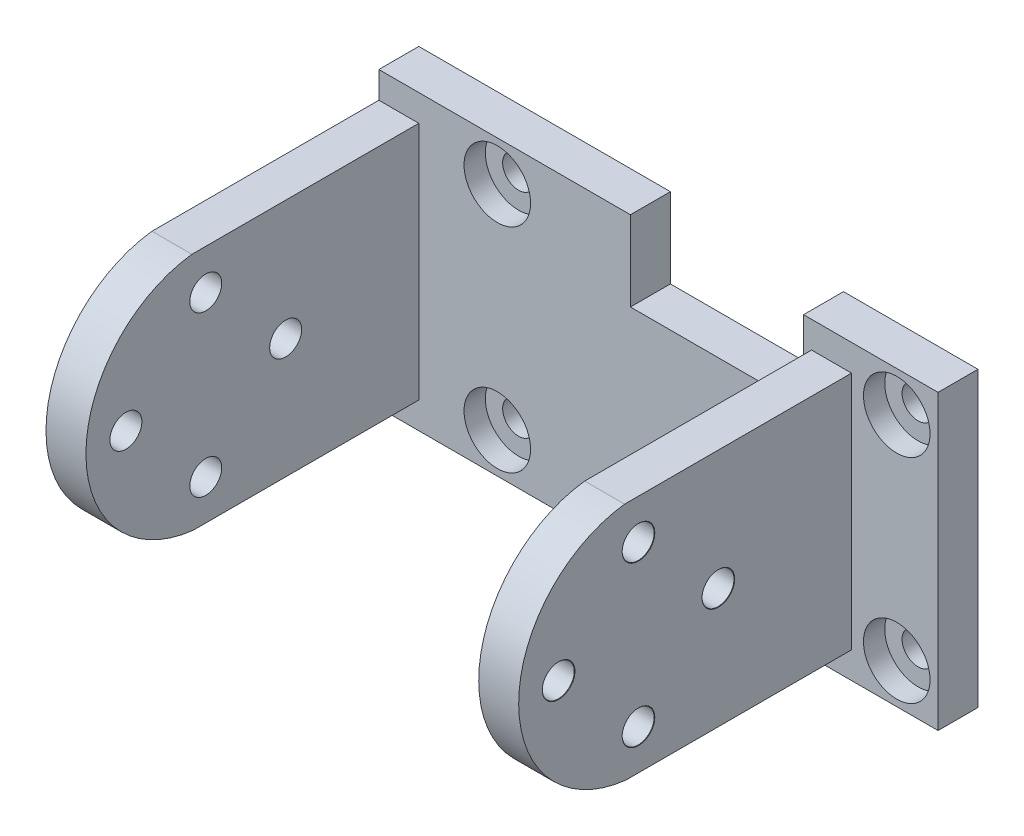
from build123d import *

# Parameters (mm, degrees)
SKETCH1_W                                        = 42
SKETCH1_H                                        = 22
BOSS_EXTRUDE1_DEPTH                              = 3
SKETCH2_W                                        = 13
SKETCH2_H                                        = 6
CUT_EXTRUDE1_DEPTH                               = 4
SKETCH3_W                                        = 13
SKETCH3_H                                        = 6
CUT_EXTRUDE2_DEPTH                               = 4
BOSS_EXTRUDE2_DEPTH                              = 3
BOSS_EXTRUDE3_DEPTH                              = 3
M2_CLEARANCE_HOLE1_D                             = 2.4
M2_CLEARANCE_HOLE1_CSINK_D                       = 2.45
M2_CLEARANCE_HOLE1_CSINK_ANGLE                   = 90
CBORE_FOR_M2_PAN_HEAD_MACHINE_SCREW1_D           = 2.4
CBORE_FOR_M2_PAN_HEAD_MACHINE_SCREW1_CBORE_D     = 5
CBORE_FOR_M2_PAN_HEAD_MACHINE_SCREW1_CBORE_DEPTH = 1.6


with BuildPart() as part:
    # Sketch1 → Boss-Extrude1 (new body)
    with BuildSketch(Plane.XY.offset(47.892560215)):
        with Locations((8.75, 222.222621224)):
            Rectangle(SKETCH1_W, SKETCH1_H)
    extrude(amount=-BOSS_EXTRUDE1_DEPTH)

    # Sketch2 → Cut-Extrude1 (cut, through all)
    with BuildSketch(Plane(origin=(0, 0, 44.892560215), x_dir=(-1, 0, 0), z_dir=(0, 0, -1))):
        with Locations((-13.146676675, 230.222621224)):
            Rectangle(SKETCH2_W, SKETCH2_H)
    extrude(amount=-CUT_EXTRUDE1_DEPTH, mode=Mode.SUBTRACT)

    # Sketch3 → Cut-Extrude2 (cut, through all)
    with BuildSketch(Plane(origin=(0, 0, 44.892560215), x_dir=(-1, 0, 0), z_dir=(0, 0, -1))):
        with Locations((-13.146676675, 214.222621224)):
            Rectangle(SKETCH3_W, SKETCH3_H)
    extrude(amount=-CUT_EXTRUDE2_DEPTH, mode=Mode.SUBTRACT)

    # Sketch4 → Boss-Extrude2 (add)
    with BuildSketch(Plane(origin=(-12.25, 0, 0), x_dir=(0, -1, 0), z_dir=(-1, 0, 0))):
        with BuildLine():
            Line((-231.222621224, 64.935707597), (-231.222621224, 47.892560215))
            Line((-231.222621224, 47.892560215), (-213.222621224, 47.892560215))
            Line((-213.222621224, 47.892560215), (-213.222621224, 64.839486293))
            ThreePointArc((-213.222621224, 64.839486293), (-222.179830351, 72.892432503), (-231.222621224, 64.935707597))
        make_face()
    extrude(amount=-BOSS_EXTRUDE2_DEPTH)

    # Sketch5 → Boss-Extrude3 (add)
    with BuildSketch(Plane(origin=(23.25, 0, 0), x_dir=(0, 0, -1), z_dir=(1, 0, 0))):
        with BuildLine():
            Line((-64.839486293, 213.222621224), (-47.892560215, 213.222621224))
            Line((-47.892560215, 213.222621224), (-47.892560215, 231.222621224))
            Line((-47.892560215, 231.222621224), (-64.935707597, 231.222621224))
            ThreePointArc((-64.935707597, 231.222621224), (-72.892432503, 222.179830351), (-64.839486293, 213.222621224))
        make_face()
    extrude(amount=-BOSS_EXTRUDE3_DEPTH)

    # M2 Clearance Hole1 (through all)
    with Locations(Plane(origin=(23.25, 0, 0), x_dir=(0, 0, -1), z_dir=(1, 0, 0))):
        with Locations((-63.892759177, 228.222223301), (-69.892560215, 222.222422263), (-63.892759177, 216.222621224), (-57.892958138, 222.222422263)):
            CounterSinkHole(M2_CLEARANCE_HOLE1_D / 2, M2_CLEARANCE_HOLE1_CSINK_D / 2, counter_sink_angle=M2_CLEARANCE_HOLE1_CSINK_ANGLE)

    # CBORE for M2 Pan Head Machine Screw1 (through all)
    with Locations(Plane.XY.offset(47.892560215)):
        with Locations((-3.353323325, 230.214980721), (-3.353323325, 214.214980721), (26.646676675, 214.214980721), (26.646676675, 230.214980721)):
            CounterBoreHole(CBORE_FOR_M2_PAN_HEAD_MACHINE_SCREW1_D / 2, CBORE_FOR_M2_PAN_HEAD_MACHINE_SCREW1_CBORE_D / 2, CBORE_FOR_M2_PAN_HEAD_MACHINE_SCREW1_CBORE_DEPTH)


solid = part.part
